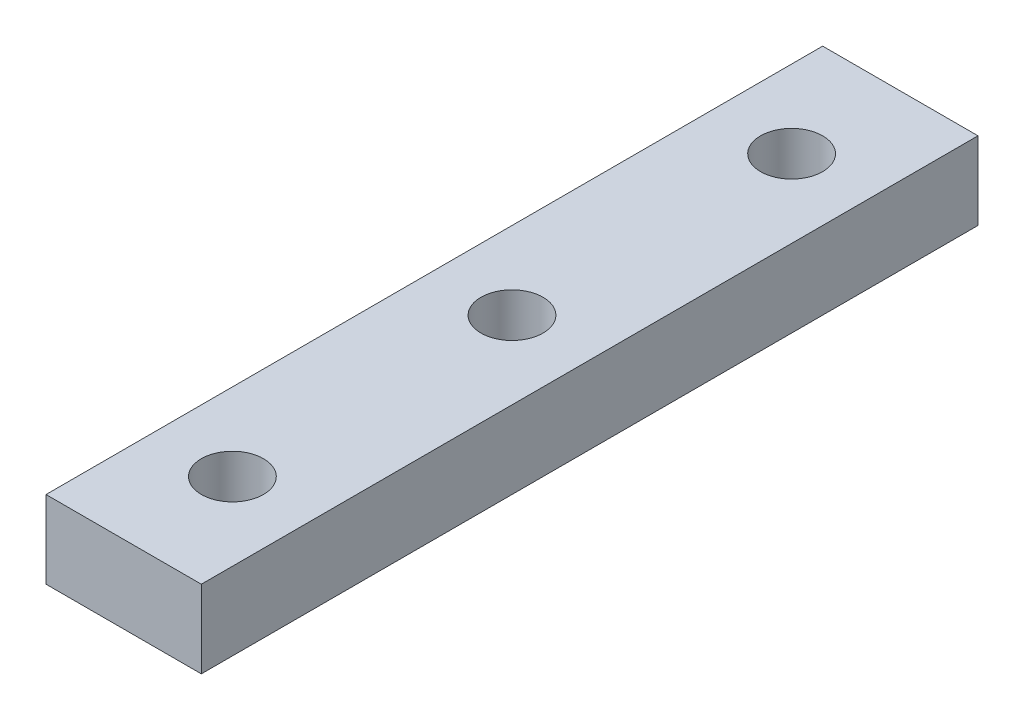
from build123d import *

# Parameters (mm, degrees)
SKETCH1_W           = 10
SKETCH1_H           = 5
BOSS_EXTRUDE1_DEPTH = 50
SKETCH2_R           = 2
CUT_EXTRUDE1_DEPTH  = 10


with BuildPart() as part:
    # Sketch1 → Boss-Extrude1 (new body)
    with BuildSketch(Plane.XY):
        Rectangle(SKETCH1_W, SKETCH1_H)
    extrude(amount=BOSS_EXTRUDE1_DEPTH)

    # Sketch2 → Cut-Extrude1 (cut)
    with BuildSketch(Plane(origin=(0, 2.5, 0), x_dir=(1, 0, 0), z_dir=(0, 1, 0))):
        with Locations((0, -43)):
            Circle(SKETCH2_R)
        with Locations((0, -25)):
            Circle(SKETCH2_R)
        with Locations((0, -7)):
            Circle(SKETCH2_R)
    extrude(amount=-CUT_EXTRUDE1_DEPTH, mode=Mode.SUBTRACT)


solid = part.part
